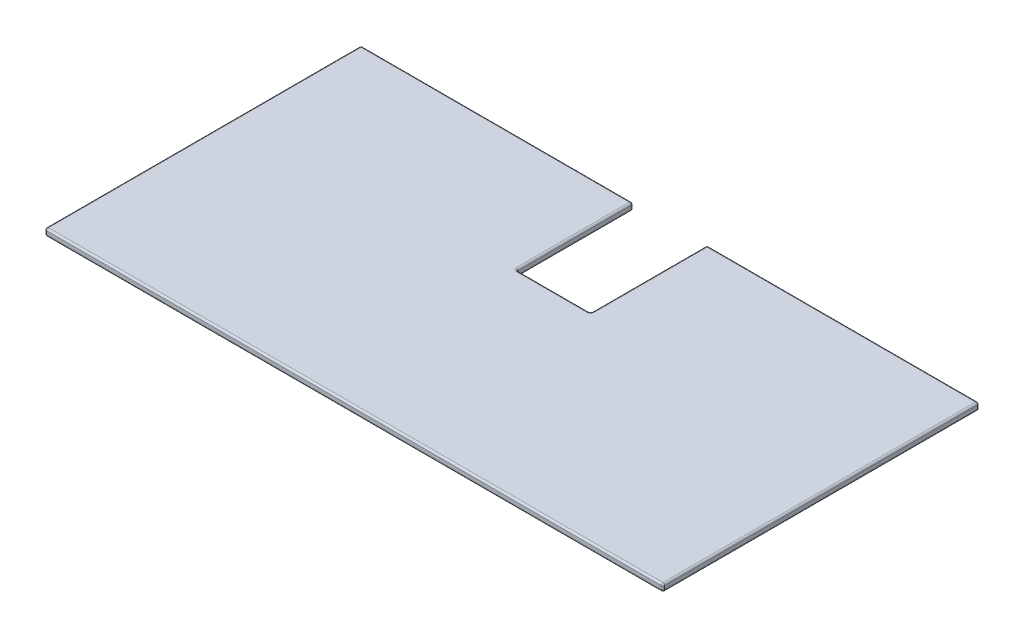
from build123d import *

# Parameters (mm, degrees)
SKETCH1_W           = 1750
SKETCH1_H           = 895
BOSS_EXTRUDE1_DEPTH = 20
SKETCH2_W           = 210
SKETCH2_H           = 660
CUT_EXTRUDE1_DEPTH  = 20
FILLET1_R           = 5


with BuildPart() as part:
    # Sketch1 → Boss-Extrude1 (new body)
    with BuildSketch(Plane(origin=(0, 0, 0), x_dir=(1, 0, 0), z_dir=(0, 1, 0))):
        Rectangle(SKETCH1_W, SKETCH1_H)
    extrude(amount=BOSS_EXTRUDE1_DEPTH)

    # Sketch2 → Cut-Extrude1 (cut)
    with BuildSketch(Plane(origin=(0, 20, 0), x_dir=(1, 0, 0), z_dir=(0, 1, 0))):
        with Locations((0, 447.5)):
            Rectangle(SKETCH2_W, SKETCH2_H)
    extrude(amount=-CUT_EXTRUDE1_DEPTH, mode=Mode.SUBTRACT)

    # Fillet1
    fillet1_edges = [part.edges().sort_by_distance(p)[0] for p in [
        (-875, 20, 0),
        (-490, 0, -447.5),
        (-105, 0, -282.5),
        (-490, 20, -447.5),
        (0, 20, 447.5),
        (105, 20, -282.5),
        (-105, 20, -282.5),
        (0, 20, -117.5),
        (105, 0, -282.5),
        (105, 10, -447.5),
        (-105, 10, -447.5),
        (-105, 10, -117.5),
        (0, 0, -117.5),
        (105, 10, -117.5),
        (875, 20, 0),
        (0, 0, 447.5),
        (-875, 0, 0),
        (490, 0, -447.5),
        (875, 0, 0),
        (875, 10, 447.5),
        (-875, 10, 447.5),
        (-875, 10, -447.5),
        (875, 10, -447.5),
        (490, 20, -447.5),
    ]]
    fillet(fillet1_edges, radius=FILLET1_R)


solid = part.part
